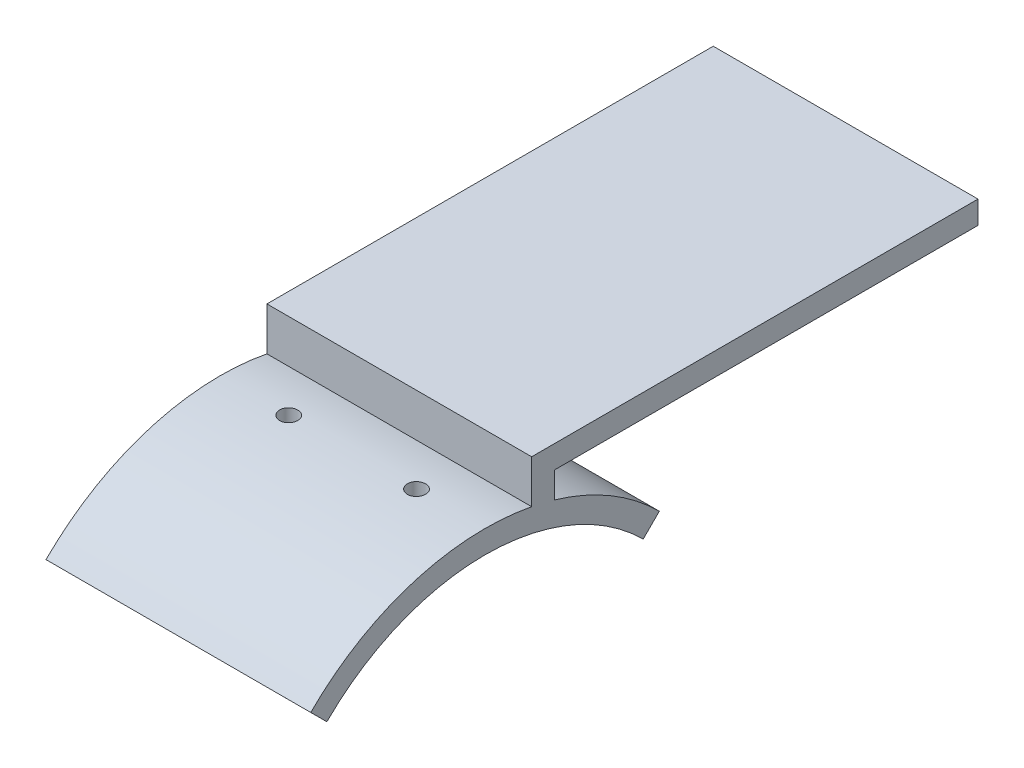
from build123d import *

# Parameters (mm, degrees)
BOSS_EXTRUDE2_DEPTH     = 58
SKETCH4_R               = 2
CUT_EXTRUDE2_DEPTH      = 58
CUT_EXTRUDE2_DEPTH_BACK = 58


with BuildPart() as part:
    # Sketch3 → Boss-Extrude2 (new body)
    with BuildSketch(Plane(origin=(0, 0, 0), x_dir=(0, 0, -1), z_dir=(1, 0, 0))):
        with BuildLine():
            Line((-34.648232278, -14.351767722), (-38.183766184, -10.816233816))
            ThreePointArc((-38.183766184, -10.816233816), (-15.829835797, 2.627669894), (10.217922448, 4.024466625))
            Line((10.217922448, 4.024466625), (10.217922448, 13.5))
            Line((10.217922448, 13.5), (108, 13.5))
            Line((108, 13.5), (108, 8.5))
            Line((108, 8.5), (15.217922448, 8.5))
            Line((15.217922448, 8.5), (15.217922448, 2.811338878))
            ThreePointArc((15.217922448, 2.811338878), (27.556537728, -2.560391599), (38.183766184, -10.816233816))
            Line((38.183766184, -10.816233816), (34.648232278, -14.351767722))
            ThreePointArc((34.648232278, -14.351767722), (0, 0), (-34.648232278, -14.351767722))
        make_face()
    extrude(amount=BOSS_EXTRUDE2_DEPTH)

    # Sketch4 → Cut-Extrude2 (cut, two sides)
    with BuildSketch(Plane(origin=(0, 0, 0), x_dir=(1, 0, 0), z_dir=(0, 1, 0))) as cut_extrude2_sk:
        with Locations((15, 0)):
            Circle(SKETCH4_R)
        with Locations((43, 0)):
            Circle(SKETCH4_R)
    extrude(amount=CUT_EXTRUDE2_DEPTH, mode=Mode.SUBTRACT)
    extrude(cut_extrude2_sk.sketch, amount=-CUT_EXTRUDE2_DEPTH_BACK, mode=Mode.SUBTRACT)


solid = part.part
